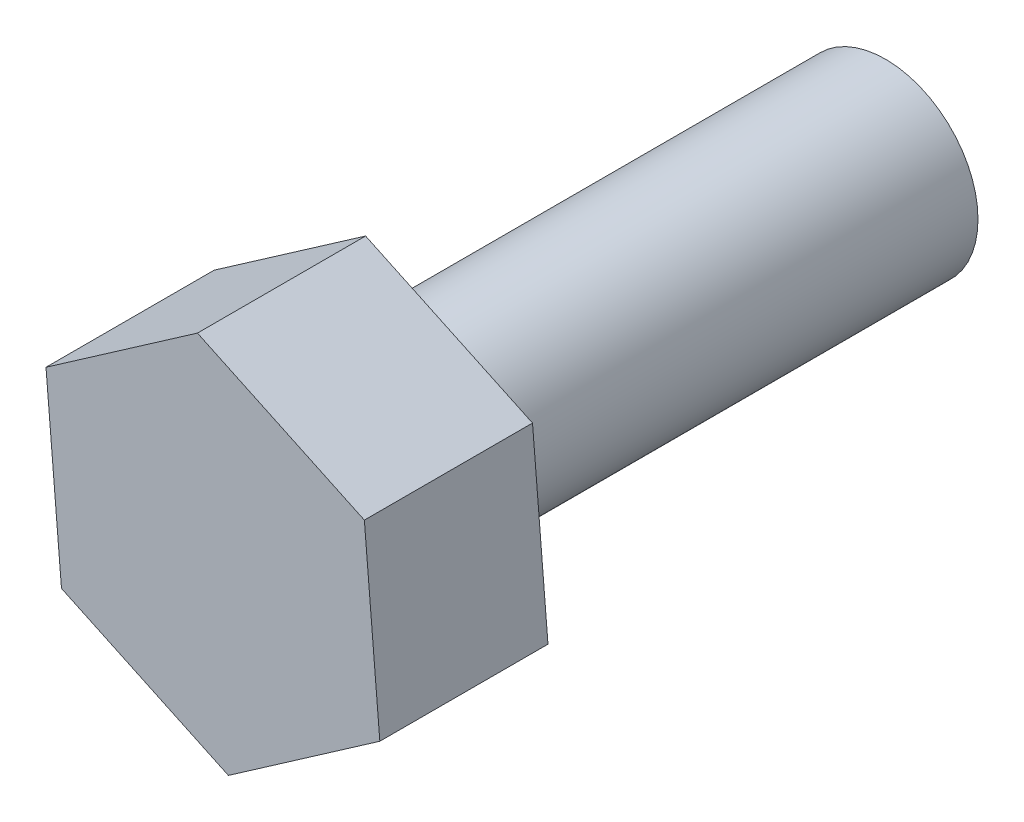
from build123d import *

# Parameters (mm, degrees)
SKETCH_1_R      = 5.5
EXTRUDE_1_DEPTH = 30
EXTRUDE_2_DEPTH = 10


with BuildPart() as part:
    # Эскиз1 → Бобышка-Вытянуть1 (new body)
    with BuildSketch(Plane.XY):
        Circle(SKETCH_1_R)
    extrude(amount=EXTRUDE_1_DEPTH)

    # Эскиз2 → Бобышка-Вытянуть2 (add)
    with BuildSketch(Plane.XY.offset(30)):
        Polygon((-9.926603377, 4.668605651), (-9.006432783, -6.262387873), (0.920170595, -10.930993523), (9.926603377, -4.668605651), (9.006432783, 6.262387873), (-0.920170595, 10.930993523), align=None)
    extrude(amount=EXTRUDE_2_DEPTH)


solid = part.part
